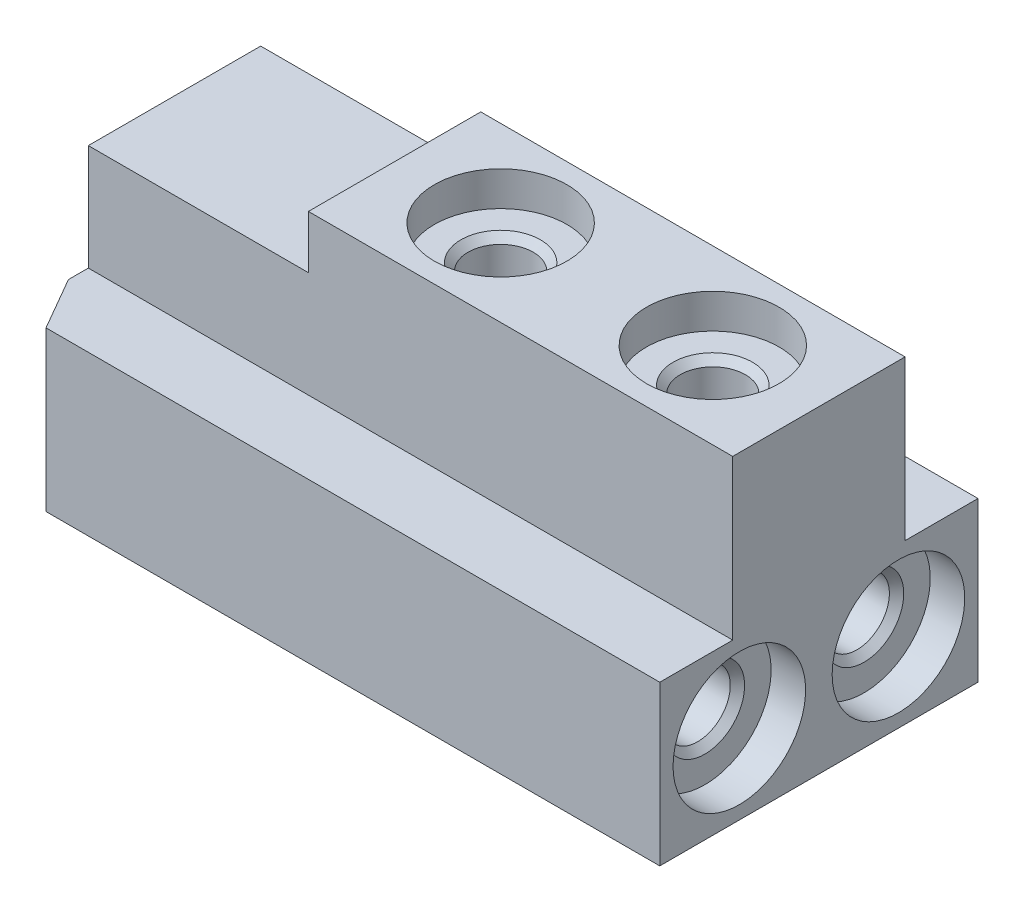
from build123d import *

# Parameters (mm, degrees)
BOSS_EXTRUDE1_DEPTH = 24.3
SKETCH2_W           = 12
SKETCH2_H           = 2
CUT_EXTRUDE1_DEPTH  = 8.3
CUT_EXTRUDE2_DEPTH  = 6


with BuildPart() as part:
    # Sketch1 → Boss-Extrude1 (new body)
    with BuildSketch(Plane(origin=(0, 0, 0), x_dir=(0, 0, -1), z_dir=(1, 0, 0))):
        Polygon((-6, 6), (-6, 0), (6, 0), (6, 6), (3.25, 6), (3.25, 12), (-3.25, 12), (-3.25, 6), align=None)
    extrude(amount=BOSS_EXTRUDE1_DEPTH)

    # Sketch2 → Cut-Extrude1 (cut)
    with BuildSketch(Plane(origin=(0, 0, 0), x_dir=(0, 0, -1), z_dir=(1, 0, 0))):
        with Locations((0, 11)):
            Rectangle(SKETCH2_W, SKETCH2_H)
    extrude(amount=CUT_EXTRUDE1_DEPTH, mode=Mode.SUBTRACT)

    # Sketch3 → Cut-Revolve1 (revolve, cut)
    with BuildSketch(Plane(origin=(0, 3, 0), x_dir=(1, 0, 0), z_dir=(0, 1, 0))):
        Polygon((15.140147844, 3), (15.85, 4.2295), (22.7295, 4.2295), (23, 4.5), (23, 5.5), (24.3, 5.5), (24.3, 3), align=None)
    revolve(axis=Axis((24.3, 3, -3), (-1, 0, 0)), mode=Mode.SUBTRACT)

    # Sketch4 → Cut-Revolve2 (revolve, cut)
    with BuildSketch(Plane(origin=(0, 3, 0), x_dir=(1, 0, 0), z_dir=(0, 1, 0))):
        Polygon((15.140147844, -3), (15.85, -1.7705), (22.7295, -1.7705), (23, -1.5), (23, -0.5), (24.3, -0.5), (24.3, -3), align=None)
    revolve(axis=Axis((24.3, 3, 3), (-1, 0, 0)), mode=Mode.SUBTRACT)

    # Sketch5 → Cut-Revolve3 (revolve, cut)
    with BuildSketch(Plane.XY):
        Polygon((20.3, 12), (22.8, 12), (22.8, 10.7), (21.8, 10.7), (21.5295, 10.4295), (21.5295, 3.55), (20.3, 2.840147844), align=None)
    revolve(axis=Axis((20.3, 2.840147844, 0), (0, 1, 0)), mode=Mode.SUBTRACT)

    # Sketch6 → Cut-Revolve4 (revolve, cut)
    with BuildSketch(Plane.XY):
        Polygon((12.3, 12), (14.8, 12), (14.8, 10.7), (13.8, 10.7), (13.5295, 10.4295), (13.5295, 3.55), (12.3, 2.840147844), align=None)
    revolve(axis=Axis((12.3, 2.840147844, 0), (0, 1, 0)), mode=Mode.SUBTRACT)

    # Sketch7 → Cut-Extrude2 (cut)
    with BuildSketch(Plane(origin=(0, 0, 0), x_dir=(1, 0, 0), z_dir=(0, 1, 0))):
        Polygon((-1, -7), (11.15, -7), (11.15, -6), (1.154700538, -6), (0, -4), (0, 4), (1.154700538, 6), (11.15, 6), (11.15, 7), (-1, 7), align=None)
    extrude(amount=CUT_EXTRUDE2_DEPTH, mode=Mode.SUBTRACT)


solid = part.part
